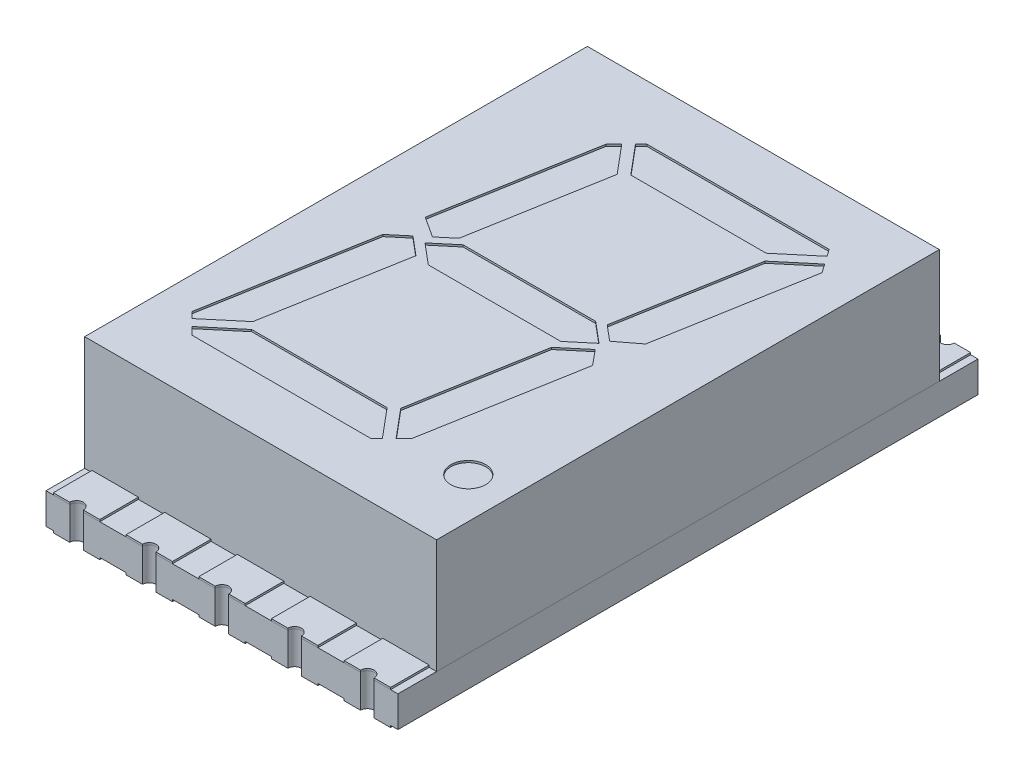
from build123d import *

# Parameters (mm, degrees)
SKETCH1_W          = 9.1
SKETCH1_H          = 13
EXTRUDE1_DEPTH     = 2.95
SKETCH6_R          = 0.45
CUT_EXTRUDE1_DEPTH = 0.05
SKETCH9_W          = 9.1
SKETCH9_H          = 15
EXTRUDE2_DEPTH     = 0.8
EXTRUDE3_DEPTH     = 0.05
EXTRUDE3_2_DEPTH   = 0.05
EXTRUDE3_3_DEPTH   = 0.05
EXTRUDE3_4_DEPTH   = 0.05
EXTRUDE3_5_DEPTH   = 0.05
EXTRUDE3_6_DEPTH   = 0.05
EXTRUDE3_7_DEPTH   = 0.05
EXTRUDE3_8_DEPTH   = 0.05
EXTRUDE3_9_DEPTH   = 0.05
EXTRUDE3_10_DEPTH  = 0.05
SKETCH11_W         = 1.2
SKETCH11_H         = 1.3
EXTRUDE4_DEPTH     = 0.05
SKETCH10_5_R       = 0.175
CUT_EXTRUDE2_DEPTH = 1.85


with BuildPart() as part:
    # Sketch1 → Extrude1 (new body)
    with BuildSketch(Plane(origin=(0, 0, 0), x_dir=(1, 0, 0), z_dir=(0, 1, 0))):
        Rectangle(SKETCH1_W, SKETCH1_H)
    extrude(amount=-EXTRUDE1_DEPTH)

    # Sketch6 → Cut-Extrude1 (cut)
    with BuildSketch(Plane(origin=(0, 0, 0), x_dir=(-1, 0, 0), z_dir=(0, 1, 0))):
        Polygon((1.916225615, -4.753756395), (2.120312095, -4.549669914), (2.820649639, -0.577858334), (2.286473327, -0.230476702), (1.912719332, -0.544093542), (1.299946124, -4.019303098), align=None)
        Polygon((1.58998201, -5.08), (1.738773661, -4.931208348), (1.108435013, -4.18), (-2.392544722, -4.18), (-3.248407181, -4.898153873), (-3.121077152, -5.08), align=None)
        Polygon((2.561144765, 0), (2.985297566, 0.355906458), (3.724771214, 4.549669914), (3.567798366, 4.706642762), (2.711935907, 3.988488889), (2.079865773, 0.403841025), align=None)
        Polygon((1.713710883, -0.45), (2.25, 0), (1.713710883, 0.45), (-1.713710883, 0.45), (-2.25, 0), (-1.713710883, -0.45), align=None)
        Polygon((-3.392349032, -4.692583605), (-2.553241625, -3.988488889), (-1.941625025, -0.519838786), (-2.339673394, -0.185836546), (-2.867499948, -0.587842972), (-3.551259479, -4.465635967), align=None)
        Polygon((2.551239005, 4.18), (3.390346412, 4.884094716), (3.194441128, 5.08), (-1.431287727, 5.08), (-1.580079379, 4.931208348), (-0.949740731, 4.18), align=None)
        Polygon((-1.726468077, 0.700376901), (-1.141251842, 4.019303098), (-1.757531332, 4.753756395), (-1.961617813, 4.549669914), (-2.661746033, 0.579045469), (-2.339492851, 0.18598804), align=None)
        with Locations(Location((-3.5, 4.63, 0), (0, 0, 90))):  # turned: the seam where the file's is
            Circle(SKETCH6_R)
    extrude(amount=-CUT_EXTRUDE1_DEPTH, mode=Mode.SUBTRACT)


with BuildPart() as body_2:
    # Sketch9 → Extrude2 (new body)
    with BuildSketch(Plane.XZ.offset(2.95)):
        Rectangle(SKETCH9_W, SKETCH9_H)
    extrude(amount=EXTRUDE2_DEPTH)

    # Sketch11 → Extrude4 (add)
    with BuildSketch(Plane.XZ.offset(3.75)):
        with Locations((-3.76, -6.85)):
            Rectangle(SKETCH11_W, SKETCH11_H)
        with Locations((-1.88, -6.85)):
            Rectangle(SKETCH11_W, SKETCH11_H)
        with Locations((0, -6.85)):
            Rectangle(SKETCH11_W, SKETCH11_H)
        with Locations((1.88, -6.85)):
            Rectangle(SKETCH11_W, SKETCH11_H)
        with Locations((3.76, -6.85)):
            Rectangle(SKETCH11_W, SKETCH11_H)
        with Locations((3.76, 6.85)):
            Rectangle(SKETCH11_W, SKETCH11_H)
        with Locations((0, 6.85)):
            Rectangle(SKETCH11_W, SKETCH11_H)
        with Locations((-1.88, 6.85)):
            Rectangle(SKETCH11_W, SKETCH11_H)
        with Locations((-3.76, 6.85)):
            Rectangle(SKETCH11_W, SKETCH11_H)
        with Locations((1.88, 6.85)):
            Rectangle(SKETCH11_W, SKETCH11_H)
    extrude(amount=EXTRUDE4_DEPTH)

    # Sketch10_5 → Cut-Extrude2 (cut, through all)
    with BuildSketch(Plane(origin=(0, -2.95, 0), x_dir=(-1, 0, 0), z_dir=(0, 1, 0))):
        with Locations((3.76, 7.5)):
            Circle(SKETCH10_5_R)
        with Locations((1.88, 7.5)):
            Circle(SKETCH10_5_R)
        with Locations((0, 7.5)):
            Circle(SKETCH10_5_R)
        with Locations((-1.88, 7.5)):
            Circle(SKETCH10_5_R)
        with Locations((-3.76, 7.5)):
            Circle(SKETCH10_5_R)
        with Locations((-3.76, -7.5)):
            Circle(SKETCH10_5_R)
        with Locations((-1.88, -7.5)):
            Circle(SKETCH10_5_R)
        with Locations((0, -7.5)):
            Circle(SKETCH10_5_R)
        with Locations((1.88, -7.5)):
            Circle(SKETCH10_5_R)
        with Locations((3.76, -7.5)):
            Circle(SKETCH10_5_R)
    extrude(amount=-CUT_EXTRUDE2_DEPTH, mode=Mode.SUBTRACT)


with BuildPart() as body_3:
    # Sketch10 → Extrude3 (new body)
    with BuildSketch(Plane(origin=(0, -2.95, 0), x_dir=(-1, 0, 0), z_dir=(0, 1, 0))):
        with BuildLine():
            Line((1.28, -6.5), (1.28, -7.5))
            Line((1.28, -7.5), (1.705, -7.5))
            ThreePointArc((1.705, -7.5), (1.88, -7.325), (2.055, -7.5))
            Line((2.055, -7.5), (2.48, -7.5))
            Line((2.48, -7.5), (2.48, -6.5))
            Line((2.48, -6.5), (1.28, -6.5))
        make_face()
    extrude(amount=EXTRUDE3_DEPTH)


with BuildPart() as body_4:
    # Sketch10 → Extrude3 2 (new body)
    with BuildSketch(Plane(origin=(0, -2.95, 0), x_dir=(-1, 0, 0), z_dir=(0, 1, 0))):
        with BuildLine():
            Line((-0.6, -6.5), (-0.6, -7.5))
            Line((-0.6, -7.5), (-0.175, -7.5))
            ThreePointArc((-0.175, -7.5), (0, -7.325), (0.175, -7.5))
            Line((0.175, -7.5), (0.6, -7.5))
            Line((0.6, -7.5), (0.6, -6.5))
            Line((0.6, -6.5), (-0.6, -6.5))
        make_face()
    extrude(amount=EXTRUDE3_2_DEPTH)


with BuildPart() as body_5:
    # Sketch10 → Extrude3 3 (new body)
    with BuildSketch(Plane(origin=(0, -2.95, 0), x_dir=(-1, 0, 0), z_dir=(0, 1, 0))):
        with BuildLine():
            Line((-2.48, -6.5), (-2.48, -7.5))
            Line((-2.48, -7.5), (-2.055, -7.5))
            ThreePointArc((-2.055, -7.5), (-1.88, -7.325), (-1.705, -7.5))
            Line((-1.705, -7.5), (-1.28, -7.5))
            Line((-1.28, -7.5), (-1.28, -6.5))
            Line((-1.28, -6.5), (-2.48, -6.5))
        make_face()
    extrude(amount=EXTRUDE3_3_DEPTH)


with BuildPart() as body_6:
    # Sketch10 → Extrude3 4 (new body)
    with BuildSketch(Plane(origin=(0, -2.95, 0), x_dir=(-1, 0, 0), z_dir=(0, 1, 0))):
        with BuildLine():
            Line((-3.16, -6.5), (-4.36, -6.5))
            Line((-4.36, -6.5), (-4.36, -7.5))
            Line((-4.36, -7.5), (-3.935, -7.5))
            ThreePointArc((-3.935, -7.5), (-3.76, -7.325), (-3.585, -7.5))
            Line((-3.585, -7.5), (-3.16, -7.5))
            Line((-3.16, -7.5), (-3.16, -6.5))
        make_face()
    extrude(amount=EXTRUDE3_4_DEPTH)


with BuildPart() as body_7:
    # Sketch10 → Extrude3 5 (new body)
    with BuildSketch(Plane(origin=(0, -2.95, 0), x_dir=(-1, 0, 0), z_dir=(0, 1, 0))):
        with BuildLine():
            Line((3.16, 6.5), (4.36, 6.5))
            Line((4.36, 6.5), (4.36, 7.5))
            Line((4.36, 7.5), (3.935, 7.5))
            ThreePointArc((3.935, 7.5), (3.76, 7.325), (3.585, 7.5))
            Line((3.585, 7.5), (3.16, 7.5))
            Line((3.16, 7.5), (3.16, 6.5))
        make_face()
    extrude(amount=EXTRUDE3_5_DEPTH)


with BuildPart() as body_8:
    # Sketch10 → Extrude3 6 (new body)
    with BuildSketch(Plane(origin=(0, -2.95, 0), x_dir=(-1, 0, 0), z_dir=(0, 1, 0))):
        with BuildLine():
            Line((2.48, 6.5), (2.48, 7.5))
            Line((2.48, 7.5), (2.055, 7.5))
            ThreePointArc((2.055, 7.5), (1.88, 7.325), (1.705, 7.5))
            Line((1.705, 7.5), (1.28, 7.5))
            Line((1.28, 7.5), (1.28, 6.5))
            Line((1.28, 6.5), (2.48, 6.5))
        make_face()
    extrude(amount=EXTRUDE3_6_DEPTH)


with BuildPart() as body_9:
    # Sketch10 → Extrude3 7 (new body)
    with BuildSketch(Plane(origin=(0, -2.95, 0), x_dir=(-1, 0, 0), z_dir=(0, 1, 0))):
        with BuildLine():
            Line((0.6, 6.5), (0.6, 7.5))
            Line((0.6, 7.5), (0.175, 7.5))
            ThreePointArc((0.175, 7.5), (0, 7.325), (-0.175, 7.5))
            Line((-0.175, 7.5), (-0.6, 7.5))
            Line((-0.6, 7.5), (-0.6, 6.5))
            Line((-0.6, 6.5), (0.6, 6.5))
        make_face()
    extrude(amount=EXTRUDE3_7_DEPTH)


with BuildPart() as body_10:
    # Sketch10 → Extrude3 8 (new body)
    with BuildSketch(Plane(origin=(0, -2.95, 0), x_dir=(-1, 0, 0), z_dir=(0, 1, 0))):
        with BuildLine():
            Line((-1.28, 6.5), (-1.28, 7.5))
            Line((-1.28, 7.5), (-1.705, 7.5))
            ThreePointArc((-1.705, 7.5), (-1.88, 7.325), (-2.055, 7.5))
            Line((-2.055, 7.5), (-2.48, 7.5))
            Line((-2.48, 7.5), (-2.48, 6.5))
            Line((-2.48, 6.5), (-1.28, 6.5))
        make_face()
    extrude(amount=EXTRUDE3_8_DEPTH)


with BuildPart() as body_11:
    # Sketch10 → Extrude3 9 (new body)
    with BuildSketch(Plane(origin=(0, -2.95, 0), x_dir=(-1, 0, 0), z_dir=(0, 1, 0))):
        with BuildLine():
            Line((-3.16, 6.5), (-3.16, 7.5))
            Line((-3.16, 7.5), (-3.585, 7.5))
            ThreePointArc((-3.585, 7.5), (-3.76, 7.325), (-3.935, 7.5))
            Line((-3.935, 7.5), (-4.36, 7.5))
            Line((-4.36, 7.5), (-4.36, 6.5))
            Line((-4.36, 6.5), (-3.16, 6.5))
        make_face()
    extrude(amount=EXTRUDE3_9_DEPTH)


with BuildPart() as body_12:
    # Sketch10 → Extrude3 10 (new body)
    with BuildSketch(Plane(origin=(0, -2.95, 0), x_dir=(-1, 0, 0), z_dir=(0, 1, 0))):
        with BuildLine():
            Line((3.16, -6.5), (3.16, -7.5))
            Line((3.16, -7.5), (3.585, -7.5))
            ThreePointArc((3.585, -7.5), (3.76, -7.325), (3.935, -7.5))
            Line((3.935, -7.5), (4.36, -7.5))
            Line((4.36, -7.5), (4.36, -6.5))
            Line((4.36, -6.5), (3.16, -6.5))
        make_face()
    extrude(amount=EXTRUDE3_10_DEPTH)


solid = Compound([part.part, body_2.part, body_3.part, body_4.part, body_5.part, body_6.part, body_7.part, body_8.part, body_9.part, body_10.part, body_11.part, body_12.part])
